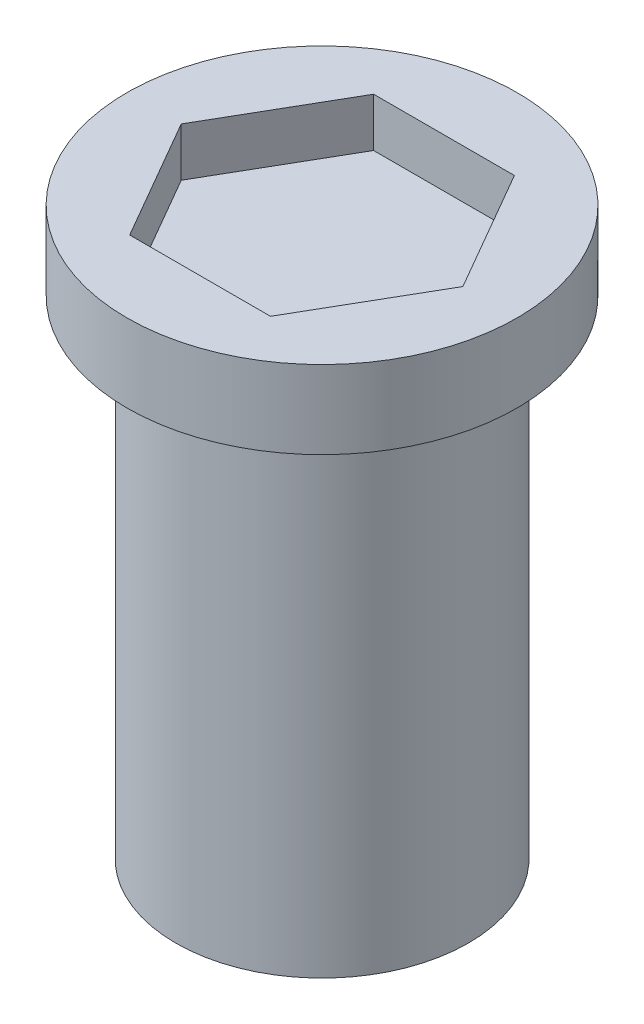
from build123d import *

# Parameters (mm, degrees)
SKETCH1_R           = 15
BOSS_EXTRUDE1_DEPTH = 50
SKETCH2_R           = 20
BOSS_EXTRUDE2_DEPTH = 8
CUT_EXTRUDE1_DEPTH  = 5


with BuildPart() as part:
    # Sketch1 → Boss-Extrude1 (new body)
    with BuildSketch(Plane(origin=(0, 0, 0), x_dir=(1, 0, 0), z_dir=(0, 1, 0))):
        Circle(SKETCH1_R)
    extrude(amount=BOSS_EXTRUDE1_DEPTH)

    # Sketch2 → Boss-Extrude2 (add)
    with BuildSketch(Plane(origin=(0, 50, 0), x_dir=(1, 0, 0), z_dir=(0, 1, 0))):
        Circle(SKETCH2_R)
    extrude(amount=BOSS_EXTRUDE2_DEPTH)

    # Sketch3 → Cut-Extrude1 (cut)
    with BuildSketch(Plane(origin=(0, 58, 0), x_dir=(1, 0, 0), z_dir=(0, 1, 0))):
        Polygon((-14.43375673, 0), (-7.216878365, -12.5), (7.216878365, -12.5), (14.43375673, 0), (7.216878365, 12.5), (-7.216878365, 12.5), align=None)
    extrude(amount=-CUT_EXTRUDE1_DEPTH, mode=Mode.SUBTRACT)


solid = part.part
